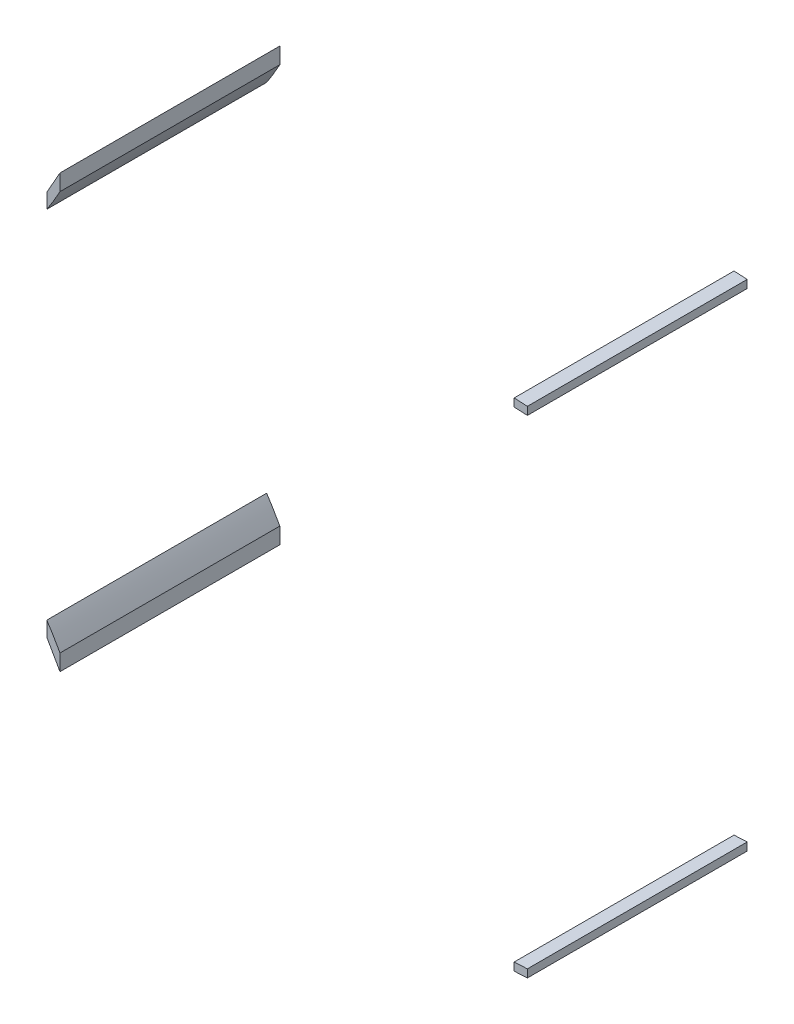
from build123d import *

# Parameters (mm, degrees)
BOSS_EXTRUDE1_DEPTH   = 50
BOSS_EXTRUDE1_2_DEPTH = 50
BOSS_EXTRUDE1_3_DEPTH = 50
BOSS_EXTRUDE1_4_DEPTH = 50


with BuildPart() as part:
    # Sketch3 → Boss-Extrude1 (new body)
    with BuildSketch(Plane.XY):
        Polygon((10.602606635, 50.209757573), (10.602606635, 52.012055288), (13.602606635, 51.860424765), (13.602606635, 50.05812705), align=None)
    extrude(amount=BOSS_EXTRUDE1_DEPTH)


with BuildPart() as body_2:
    # Sketch3 → Boss-Extrude1 2 (new body)
    with BuildSketch(Plane.XY):
        with BuildLine():
            Line((-92.697393356, -49.878847446), (-92.697393356, -53.565685001))
            add(Edge.make_bspline(
                [(-95.697393356, -48.266224595), (-94.658566007, -50.009324516), (-93.700656209, -51.801163514), (-92.697393356, -53.565685001)],
                knots=[0, 0, 0, 0, 0.230072601, 0.230072601, 0.230072601, 0.230072601], degree=3))
            Line((-95.697393356, -48.266224595), (-95.697393356, -44.8989813))
            add(Edge.make_bspline(
                [(-92.697393356, -49.878847446), (-93.643617645, -48.187277247), (-94.609063153, -46.50700723), (-95.697393356, -44.8989813)],
                knots=[0.788966629, 0.788966629, 0.788966629, 0.788966629, 1, 1, 1, 1], degree=3))
        make_face()
    extrude(amount=BOSS_EXTRUDE1_2_DEPTH)


with BuildPart() as body_3:
    # Sketch3 → Boss-Extrude1 3 (new body)
    with BuildSketch(Plane.XY):
        Polygon((10.602606635, -59.096013497), (10.602606635, -60.898311212), (13.602606635, -60.746680689), (13.602606635, -58.944382974), align=None)
    extrude(amount=BOSS_EXTRUDE1_3_DEPTH)


with BuildPart() as body_4:
    # Sketch3 → Boss-Extrude1 4 (new body)
    with BuildSketch(Plane.XY):
        with BuildLine():
            Line((-92.697393356, 40.992591522), (-92.697393362, 44.679429081))
            add(Edge.make_bspline(
                [(-95.697393356, 39.379968671), (-94.658566009, 41.123068593), (-93.700656214, 42.914907592), (-92.697393362, 44.679429081)],
                knots=[0, 0, 0, 0, 0.230072601, 0.230072601, 0.230072601, 0.230072601], degree=3))
            Line((-95.697393356, 39.379968671), (-95.697393356, 36.012725375))
            add(Edge.make_bspline(
                [(-92.697393356, 40.992591522), (-93.643617645, 39.301021323), (-94.609063153, 37.620751306), (-95.697393356, 36.012725375)],
                knots=[0.788966629, 0.788966629, 0.788966629, 0.788966629, 1, 1, 1, 1], degree=3))
        make_face()
    extrude(amount=BOSS_EXTRUDE1_4_DEPTH)


solid = Compound([part.part, body_2.part, body_3.part, body_4.part])
